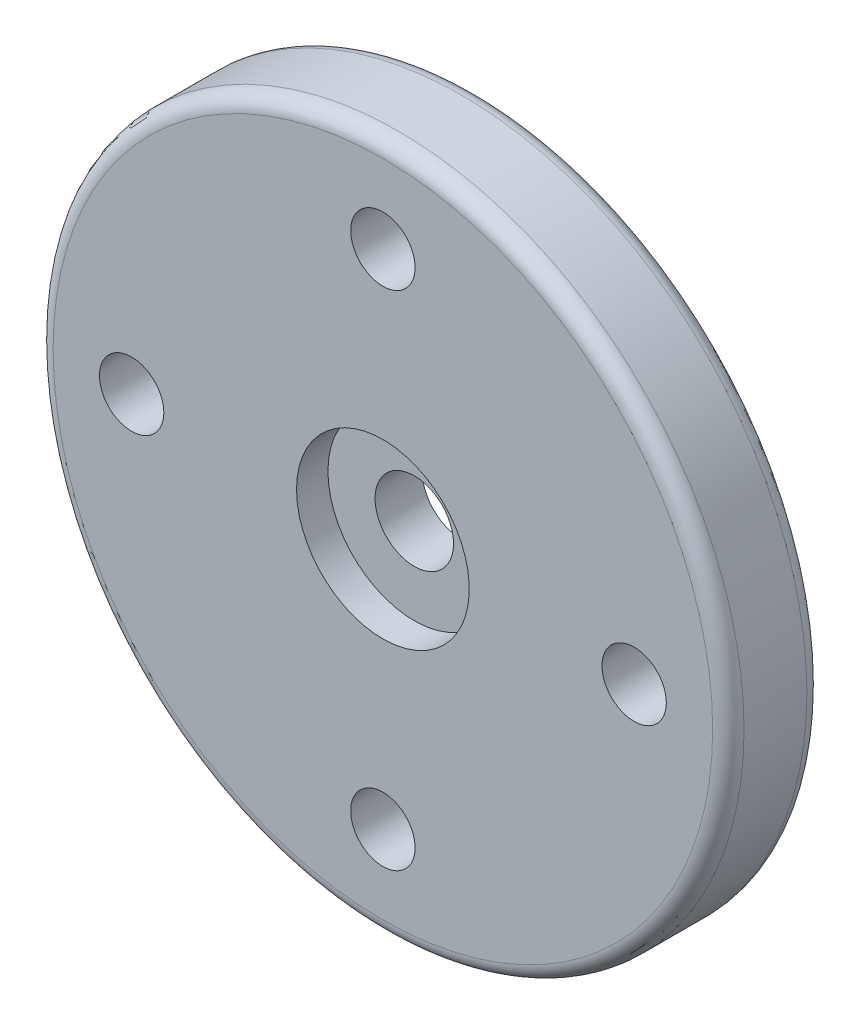
from build123d import *

# Parameters (mm, degrees)
M2_TAPPED_HOLE1_AT_2_COUNT = 2
M2_TAPPED_HOLE1_AT_2_PITCH = 11.313708499
M2_TAPPED_HOLE1_AT_3_COUNT = 2
M2_TAPPED_HOLE1_AT_3_PITCH = 16
M2_TAPPED_HOLE1_AT_4_COUNT = 2
M2_TAPPED_HOLE1_AT_4_PITCH = 11.313708499
M2_TAPPED_HOLE1_AT_5_COUNT = 2
M2_TAPPED_HOLE1_AT_5_PITCH = 8
RADYUS1_R                  = 0.5
IZIM1_R                    = 1.025
KES_EKSTR_ZYON1_DEPTH      = 10


with BuildPart() as part:
    # Sketch1 → Revolve1 (revolve)
    with BuildSketch(Plane(origin=(0, 0, 0), x_dir=(0, 0, -1), z_dir=(1, 0, 0))):
        Polygon((2.5, 1.25), (1, 1.25), (1, 2.75), (0, 2.75), (0, 11), (3, 11), (3, 2.75), (2.5, 2.75), align=None)
    revolve(axis=Axis((0, 0, 0), (0, 0, 1)))

    # Sketch4 → M2 Tapped Hole1 (revolve, cut)
    with BuildSketch(Plane(origin=(0, 8, 0), x_dir=(0, -1, 0), z_dir=(1, 0, 0))):
        Polygon((0, 0), (0, 3), (1.025, 3), (0.8, 2.870096189), (0.8, 0.129903811), (1.025, 0), align=None)
    m2_tapped_hole1 = revolve(axis=Axis((0, 8, 6.35), (0, 0, -1)), mode=Mode.SUBTRACT)

    # M2 Tapped Hole1 at 2: M2 Tapped Hole1 ×2
    with Locations(*[Vector(0.707106781, -0.707106781, 0) * (i * M2_TAPPED_HOLE1_AT_2_PITCH) for i in range(1, M2_TAPPED_HOLE1_AT_2_COUNT)]):
        add(m2_tapped_hole1, mode=Mode.SUBTRACT)

    # M2 Tapped Hole1 at 3: M2 Tapped Hole1 ×2
    with Locations(*[(0, -i * M2_TAPPED_HOLE1_AT_3_PITCH, 0) for i in range(1, M2_TAPPED_HOLE1_AT_3_COUNT)]):
        add(m2_tapped_hole1, mode=Mode.SUBTRACT)

    # M2 Tapped Hole1 at 4: M2 Tapped Hole1 ×2
    with Locations(*[Vector(-0.707106781, -0.707106781, 0) * (i * M2_TAPPED_HOLE1_AT_4_PITCH) for i in range(1, M2_TAPPED_HOLE1_AT_4_COUNT)]):
        add(m2_tapped_hole1, mode=Mode.SUBTRACT)

    # M2 Tapped Hole1 at 5: M2 Tapped Hole1 ×2
    with Locations(*[(0, -i * M2_TAPPED_HOLE1_AT_5_PITCH, 0) for i in range(1, M2_TAPPED_HOLE1_AT_5_COUNT)]):
        add(m2_tapped_hole1, mode=Mode.SUBTRACT)

    # Radyus1
    radyus1_edges = [part.edges().sort_by_distance(p)[0] for p in [
        (0, -11, -3),
        (0, -11, 0),
    ]]
    fillet(radyus1_edges, radius=RADYUS1_R)

    # Çizim1 → Kes-Ekstrüzyon1 (cut)
    with BuildSketch(Plane.XY):
        with Locations((0, 8)):
            Circle(IZIM1_R)
        with Locations((-8, 0)):
            Circle(IZIM1_R)
        with Locations((8, 0)):
            Circle(IZIM1_R)
        with Locations((0, -8)):
            Circle(IZIM1_R)
    extrude(amount=-KES_EKSTR_ZYON1_DEPTH, mode=Mode.SUBTRACT)


solid = part.part
